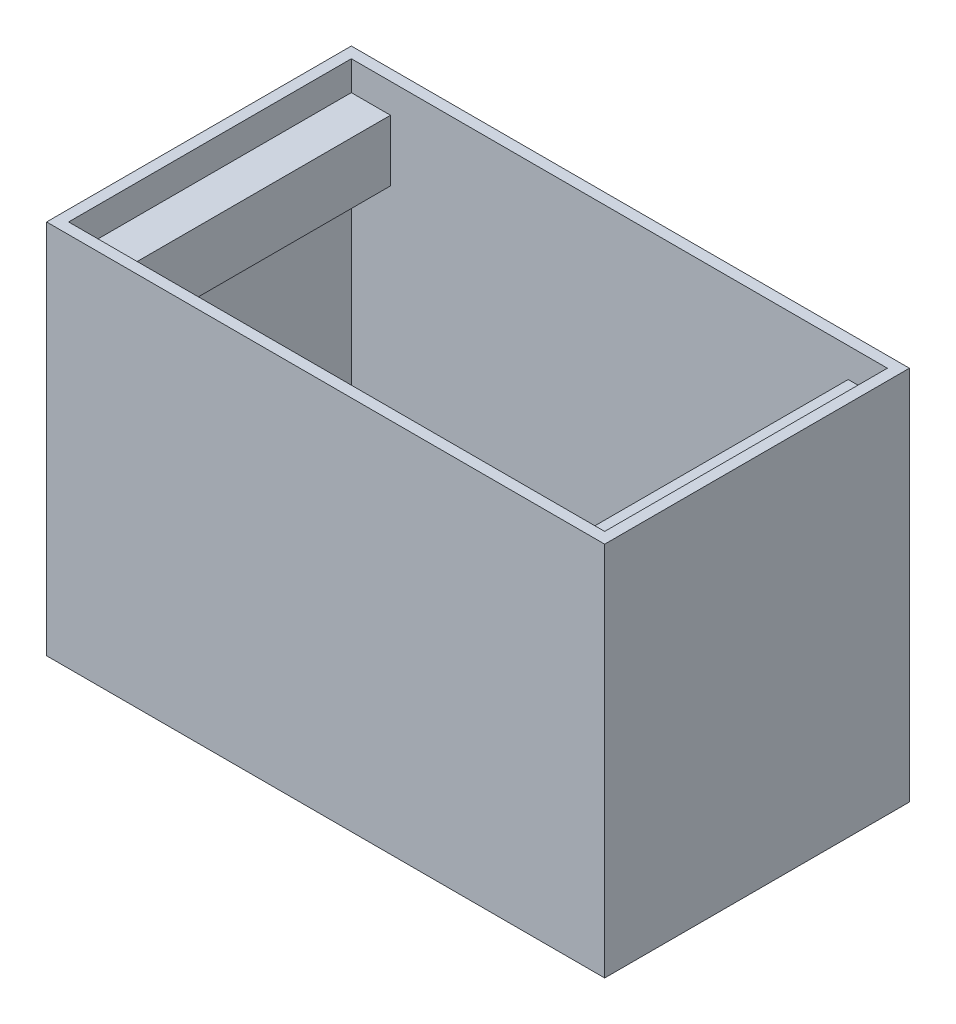
from build123d import *

# Parameters (mm, degrees)
SKETCH1_W           = 456
SKETCH1_H           = 249
SKETCH1_W_2         = 438
SKETCH1_H_2         = 231
BOSS_EXTRUDE1_DEPTH = 9
SKETCH1_3_W         = 456
SKETCH1_3_H         = 249
SKETCH1_3_W_2       = 438
SKETCH1_3_H_2       = 231
BOSS_EXTRUDE2_DEPTH = 298
SKETCH3_W           = 231
SKETCH3_H           = 50
BOSS_EXTRUDE3_DEPTH = 32


with BuildPart() as part:
    # Sketch1 → Boss-Extrude1 (new body)
    with BuildSketch(Plane(origin=(0, 0, 0), x_dir=(1, 0, 0), z_dir=(0, 1, 0))):
        Rectangle(SKETCH1_W, SKETCH1_H)
        Rectangle(SKETCH1_W_2, SKETCH1_H_2, mode=Mode.SUBTRACT)
        Rectangle(SKETCH1_W_2, SKETCH1_H_2)
    extrude(amount=-BOSS_EXTRUDE1_DEPTH)

    # Sketch1_3 → Boss-Extrude2 (add)
    with BuildSketch(Plane(origin=(0, 0, 0), x_dir=(1, 0, 0), z_dir=(0, 1, 0))):
        Rectangle(SKETCH1_3_W, SKETCH1_3_H)
        Rectangle(SKETCH1_3_W_2, SKETCH1_3_H_2, mode=Mode.SUBTRACT)
    extrude(amount=BOSS_EXTRUDE2_DEPTH)

    # Sketch3 → Boss-Extrude3 (add)
    with BuildSketch(Plane(origin=(-219, 0, 0), x_dir=(0, 0, -1), z_dir=(1, 0, 0))):
        with Locations((0, 249)):
            Rectangle(SKETCH3_W, SKETCH3_H)
    boss_extrude3 = extrude(amount=BOSS_EXTRUDE3_DEPTH)

    # Mirror1: Boss-Extrude3 across plane
    add(boss_extrude3.mirror(Plane(origin=(0, 0, 0), x_dir=(0, 0, 1), z_dir=(1, 0, 0))))


solid = part.part
